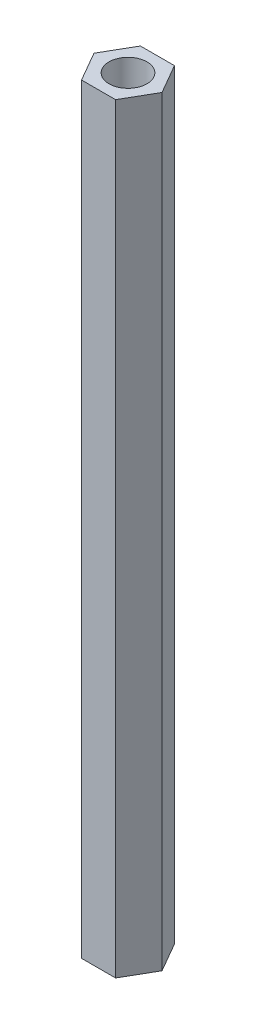
from build123d import *

# Parameters (mm, degrees)
SKETCH1_R           = 1.5
BOSS_EXTRUDE1_DEPTH = 60


with BuildPart() as part:
    # Sketch1 → Boss-Extrude1 (new body)
    with BuildSketch(Plane(origin=(0, 0, 0), x_dir=(1, 0, 0), z_dir=(0, 1, 0))):
        Polygon((1.341379, 2.32333658), (2.682757999, 0), (1.341379, -2.32333658), (-1.341379, -2.32333658), (-2.682757999, 0), (-1.341379, 2.32333658), align=None)
        Circle(SKETCH1_R, mode=Mode.SUBTRACT)
    extrude(amount=BOSS_EXTRUDE1_DEPTH)


solid = part.part
